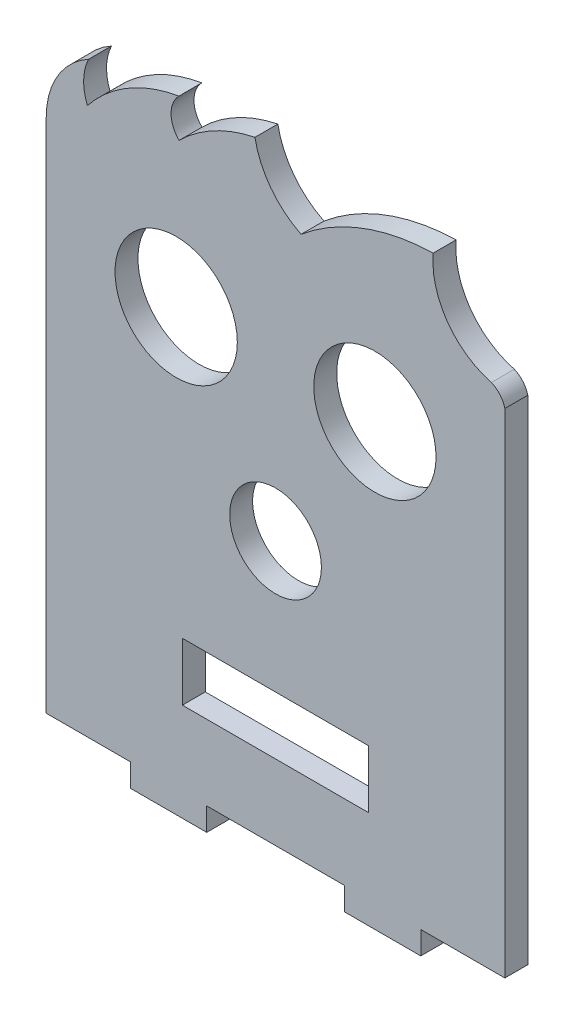
from build123d import *

# Parameters (mm, degrees)
MODEL_R                 = 8
MODEL_R_2               = 6
MODEL_W                 = 24.38
MODEL_H                 = 7.58
SALIENTE_EXTRUIR1_DEPTH = 3


with BuildPart() as part:
    # Model → Saliente-Extruir1 (new body)
    with BuildSketch(Plane.XY):
        with BuildLine():
            Line((11, -3), (21, -3))
            Line((21, -3), (21, 0))
            Line((21, 0), (39, 0))
            Line((39, 0), (39, -3))
            Line((39, -3), (49, -3))
            Line((49, -3), (49, 0))
            Line((49, 0), (60, 0))
            Line((60, 0), (60, 64.525075061))
            ThreePointArc((60, 64.525075061), (59.367904368, 65.768881419), (58.24156757, 66.592267452))
            ThreePointArc((58.24156757, 66.592267452), (52.456145593, 70.630164346), (50.622765109, 77.442978358))
            ThreePointArc((50.622765109, 77.442978358), (41.429140717, 75.658422531), (33.342205195, 70.935198758))
            ThreePointArc((33.342205195, 70.935198758), (29.382797484, 74.208773689), (27.305382782, 78.907449077))
            ThreePointArc((27.305382782, 78.907449077), (21.957335965, 76.972641815), (17.379828576, 73.597510706))
            ThreePointArc((17.379828576, 73.597510706), (16.332778743, 76.092709519), (17.356774707, 78.597457558))
            ThreePointArc((17.356774707, 78.597457558), (10.717974601, 76.180887797), (5.38917768, 71.542202679))
            ThreePointArc((5.38917768, 71.542202679), (4.894477072, 74.219269154), (5.536201967, 76.864945392))
            ThreePointArc((5.536201967, 76.864945392), (1.487784828, 72.953916782), (0, 67.525075061))
            Line((0, 67.525075061), (0, 57.374648319))
            Line((0, 57.374648319), (0, 33.26253753))
            Line((0, 33.26253753), (0, 11.520097779))
            Line((0, 11.520097779), (0, 0))
            Line((0, 0), (11, 0))
            Line((11, 0), (11, -3))
        make_face()
        with Locations((43, 54.525075061)):
            Circle(MODEL_R, mode=Mode.SUBTRACT)
        with Locations((17, 54.525075061)):
            Circle(MODEL_R, mode=Mode.SUBTRACT)
        with Locations((30, 34.525075061)):
            Circle(MODEL_R_2, mode=Mode.SUBTRACT)
        with Locations((30, 13.609080994)):
            Rectangle(MODEL_W, MODEL_H, mode=Mode.SUBTRACT)
    extrude(amount=SALIENTE_EXTRUIR1_DEPTH)


solid = part.part
